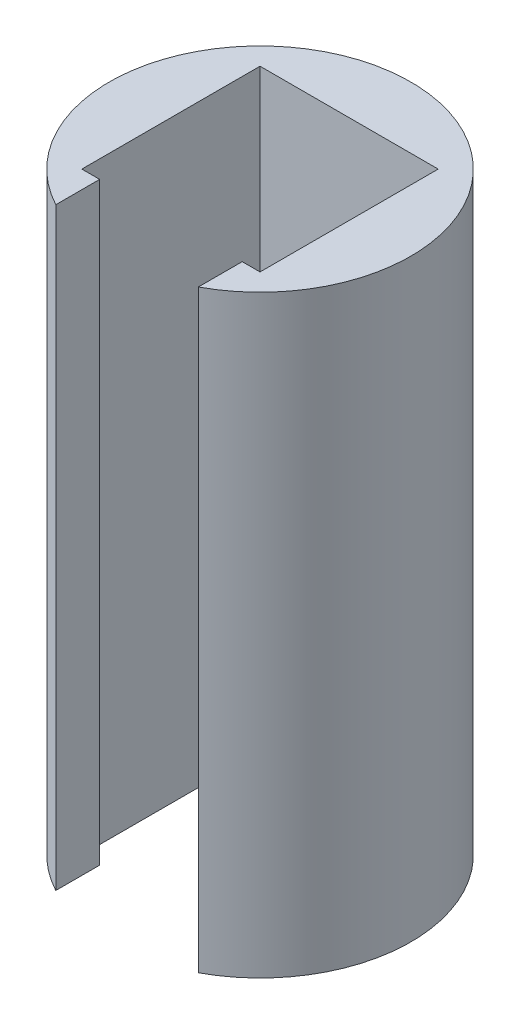
from build123d import *

# Parameters (mm, degrees)
BOSS_EXTRUDE2_DEPTH = 50


with BuildPart() as part:
    # Sketch1 → Boss-Extrude2 (new body)
    with BuildSketch(Plane(origin=(0, 0, 0), x_dir=(1, 0, 0), z_dir=(0, 1, 0))):
        with BuildLine():
            Line((5.999643171, -7.5), (7.5, -7.5))
            Line((7.5, -7.5), (7.5, 7.5))
            Line((7.5, 7.5), (-7.5, 7.5))
            Line((-7.5, 7.5), (-7.5, -7.5))
            Line((-7.5, -7.5), (-5.999643171, -7.5))
            Line((-5.999643171, -7.5), (-5.999643171, -11.193492834))
            ThreePointArc((-5.999643171, -11.193492834), (0, 12.7), (5.999643171, -11.193492834))
            Line((5.999643171, -11.193492834), (5.999643171, -7.5))
        make_face()
    extrude(amount=BOSS_EXTRUDE2_DEPTH)


solid = part.part
